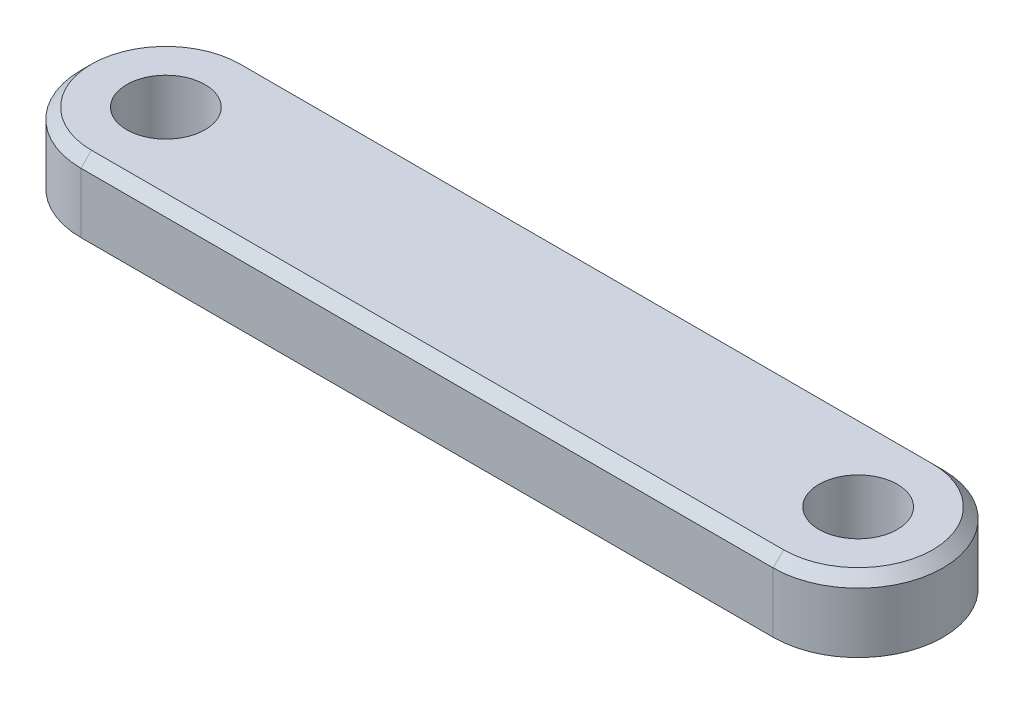
from build123d import *

# Parameters (mm, degrees)
SKETCH1_R           = 1.5
BOSS_EXTRUDE1_DEPTH = 1.35
CHAMFER1_SIZE       = 0.4


with BuildPart() as part:
    # Sketch1 → Boss-Extrude1 (new body, symmetric)
    with BuildSketch(Plane(origin=(0, 0, 0), x_dir=(1, 0, 0), z_dir=(0, 1, 0))):
        with BuildLine():
            Line((-13.25, 3.25), (13.25, 3.25))
            ThreePointArc((13.25, 3.25), (16.5, 0), (13.25, -3.25))
            Line((13.25, -3.25), (-13.25, -3.25))
            ThreePointArc((-13.25, -3.25), (-16.5, 0), (-13.25, 3.25))
        make_face()
        with Locations((-13.25, 0)):
            Circle(SKETCH1_R, mode=Mode.SUBTRACT)
        with Locations((13.25, 0)):
            Circle(SKETCH1_R, mode=Mode.SUBTRACT)
    extrude(amount=BOSS_EXTRUDE1_DEPTH, both=True)

    # Chamfer1
    chamfer1_edges = [part.edges().sort_by_distance(p)[0] for p in [
        (16.5, 1.35, 0),
        (0, 1.35, -3.25),
        (-16.5, 1.35, 0),
        (0, 1.35, 3.25),
    ]]
    chamfer(chamfer1_edges, length=CHAMFER1_SIZE)


solid = part.part
